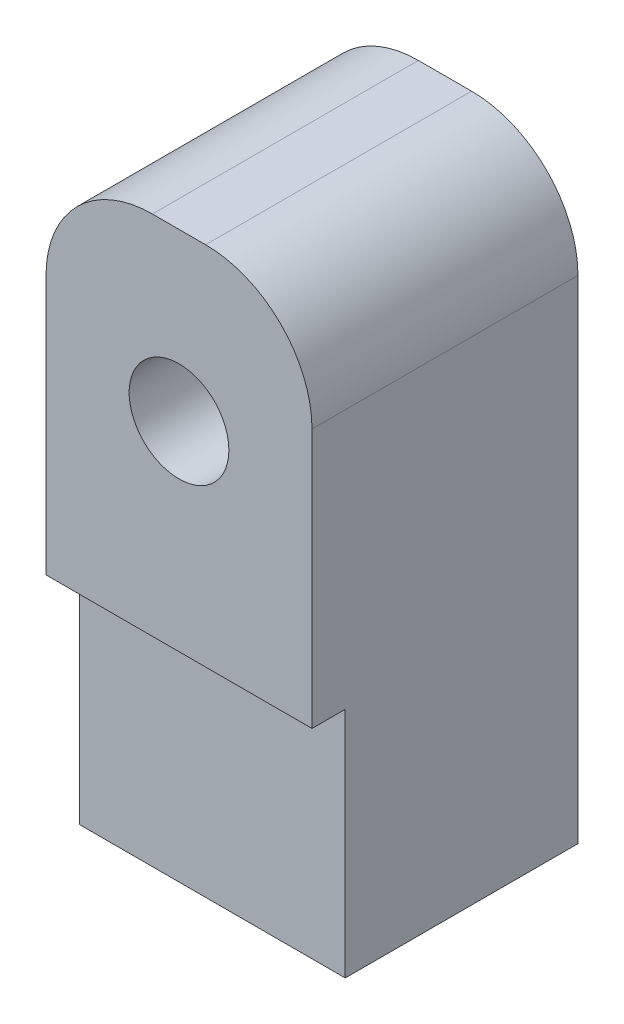
from build123d import *

# Parameters (mm, degrees)
BOSS_EXTRUDE1_DEPTH = 25.4
SKETCH1_3_R         = 4.7625
CUT_EXTRUDE1_DEPTH  = 22.225
SKETCH2_R           = 6.0325
CUT_EXTRUDE2_DEPTH  = 63.620788282
SKETCH3_W           = 3.175
SKETCH3_H           = 22.225
CUT_EXTRUDE4_DEPTH  = 68.501425911
SKETCH4_R           = 6.35
CUT_EXTRUDE5_DEPTH  = 30.1752


with BuildPart() as part:
    # Sketch1 → Boss-Extrude1 (new body)
    with BuildSketch(Plane.XY):
        with BuildLine():
            Line((-12.7, 46.99), (-12.7, 0))
            Line((-12.7, 0), (12.7, 0))
            Line((12.7, 0), (12.7, 46.99))
            ThreePointArc((12.7, 46.99), (9.724204897, 54.174204897), (2.54, 57.15))
            Line((2.54, 57.15), (-2.54, 57.15))
            ThreePointArc((-2.54, 57.15), (-9.724204897, 54.174204897), (-12.7, 46.99))
        make_face()
    extrude(amount=-BOSS_EXTRUDE1_DEPTH)

    # Sketch1_3 → Cut-Extrude1 (cut)
    with BuildSketch(Plane.XY):
        with Locations((0, 41.275)):
            Circle(SKETCH1_3_R)
    extrude(amount=-CUT_EXTRUDE1_DEPTH, mode=Mode.SUBTRACT)

    # Sketch2 → Cut-Extrude2 (cut, through all)
    with BuildSketch(Plane.XY.offset(-22.225)):
        with Locations((0, 41.275)):
            Circle(SKETCH2_R)
    extrude(amount=-CUT_EXTRUDE2_DEPTH, mode=Mode.SUBTRACT)

    # Sketch3 → Cut-Extrude4 (cut, through all)
    with BuildSketch(Plane(origin=(12.7, 0, 0), x_dir=(0, 0, -1), z_dir=(1, 0, 0))):
        with Locations((1.5875, 11.1125)):
            Rectangle(SKETCH3_W, SKETCH3_H)
    extrude(amount=-CUT_EXTRUDE4_DEPTH, mode=Mode.SUBTRACT)

    # Sketch4 → Cut-Extrude5 (cut)
    with BuildSketch(Plane.XZ):
        with Locations((0, -12.7)):
            Circle(SKETCH4_R)
    extrude(amount=-CUT_EXTRUDE5_DEPTH, mode=Mode.SUBTRACT)


solid = part.part
